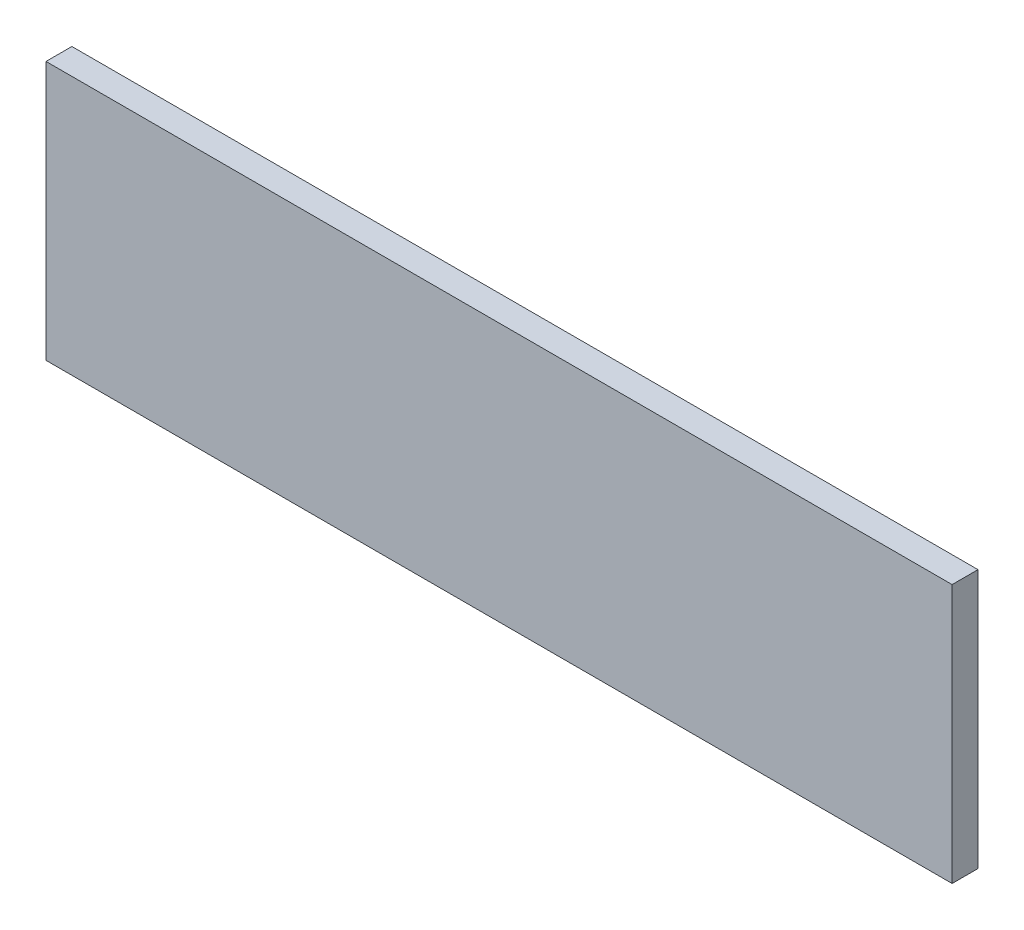
from build123d import *

# Parameters (mm, degrees)
SKETCH_1_W      = 70
SKETCH_1_H      = 20
EXTRUDE_1_DEPTH = 2


with BuildPart() as part:
    # Эскиз1 → Бобышка-Вытянуть1 (new body)
    with BuildSketch(Plane.XY):
        with Locations((35, -10)):
            Rectangle(SKETCH_1_W, SKETCH_1_H)
    extrude(amount=EXTRUDE_1_DEPTH)


solid = part.part
